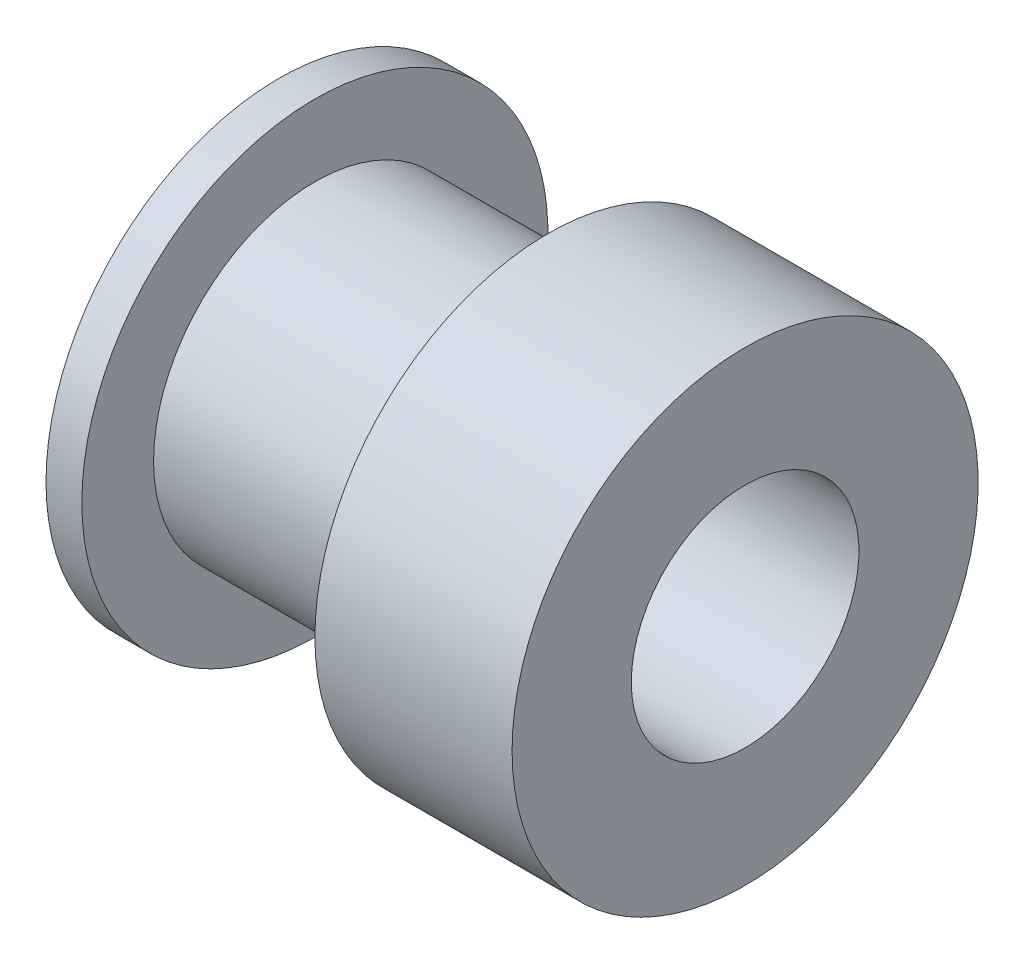
from build123d import *

# Parameters (mm, degrees)
SKETCH_2_R          = 3.175
CUT_EXTRUDE_1_DEPTH = 14


with BuildPart() as part:
    # 草图1 → 旋转1 (revolve)
    with BuildSketch(Plane.XY):
        Polygon((6.5, -3.25), (-6.5, -3.25), (-6.5, 3.25), (-5.5, 3.25), (-5.5, 1.25), (1, 1.25), (1, 3.25), (6.5, 3.25), align=None)
    revolve(axis=Axis((-6.5, -3.25, 0), (1, 0, 0)))

    # 草图2 → 切除-拉伸1 (cut, through all)
    with BuildSketch(Plane.ZY.offset(6.5)):
        with Locations((0, -3.25)):
            Circle(SKETCH_2_R)
    extrude(amount=-CUT_EXTRUDE_1_DEPTH, mode=Mode.SUBTRACT)


solid = part.part
